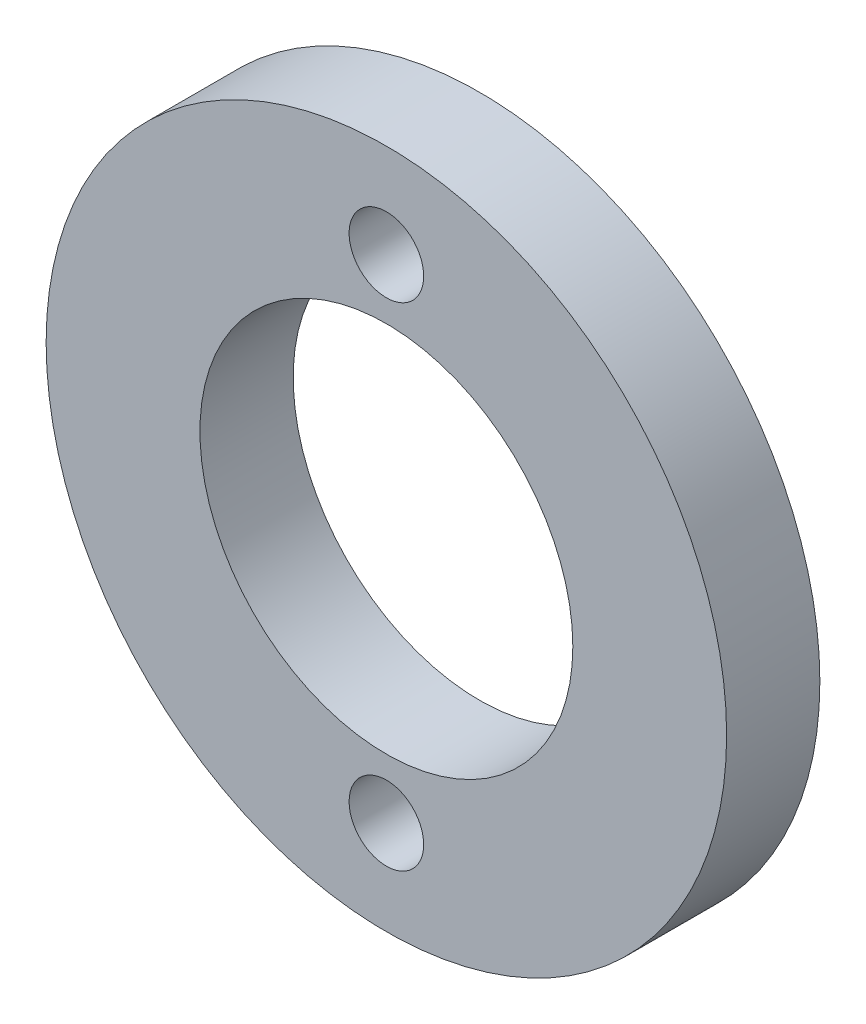
from build123d import *

# Parameters (mm, degrees)
SKETCH1_R           = 18.25
SKETCH1_R_2         = 2
SKETCH1_R_3         = 10
BOSS_EXTRUDE1_DEPTH = 5


with BuildPart() as part:
    # Sketch1 → Boss-Extrude1 (new body)
    with BuildSketch(Plane.XY):
        Circle(SKETCH1_R)
        with Locations((0, 13.2)):
            Circle(SKETCH1_R_2, mode=Mode.SUBTRACT)
        with Locations((0, -13.2)):
            Circle(SKETCH1_R_2, mode=Mode.SUBTRACT)
        Circle(SKETCH1_R_3, mode=Mode.SUBTRACT)
    extrude(amount=BOSS_EXTRUDE1_DEPTH)


solid = part.part
